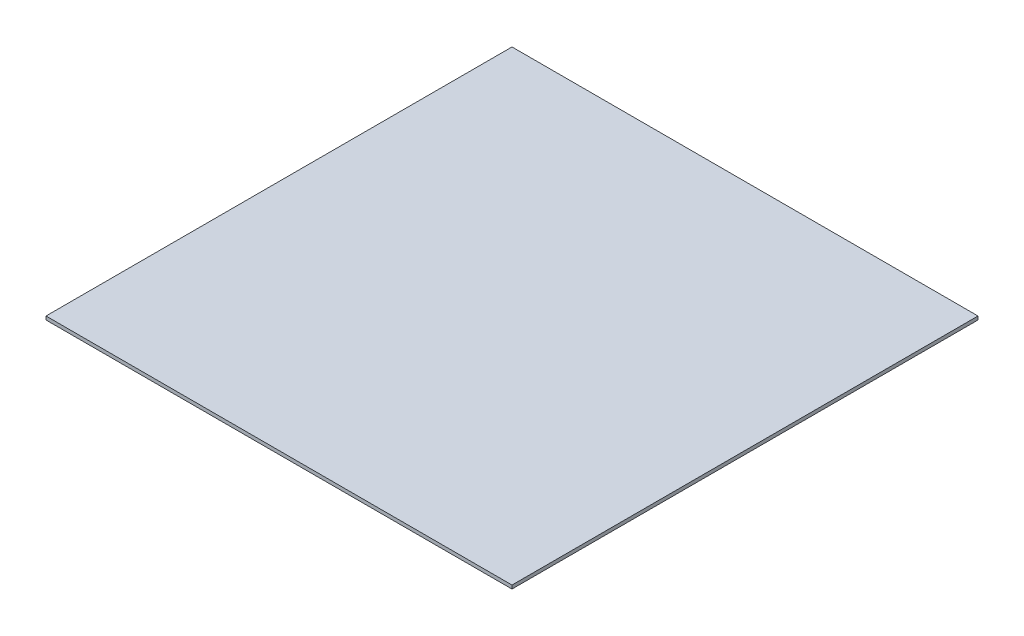
from build123d import *

# Parameters (mm, degrees)
SKETCH1_W           = 400
SKETCH1_H           = 400
BOSS_EXTRUDE1_DEPTH = 3


with BuildPart() as part:
    # Sketch1 → Boss-Extrude1 (new body)
    with BuildSketch(Plane(origin=(0, 0, 0), x_dir=(1, 0, 0), z_dir=(0, 1, 0))):
        Rectangle(SKETCH1_W, SKETCH1_H)
    extrude(amount=BOSS_EXTRUDE1_DEPTH)


solid = part.part
